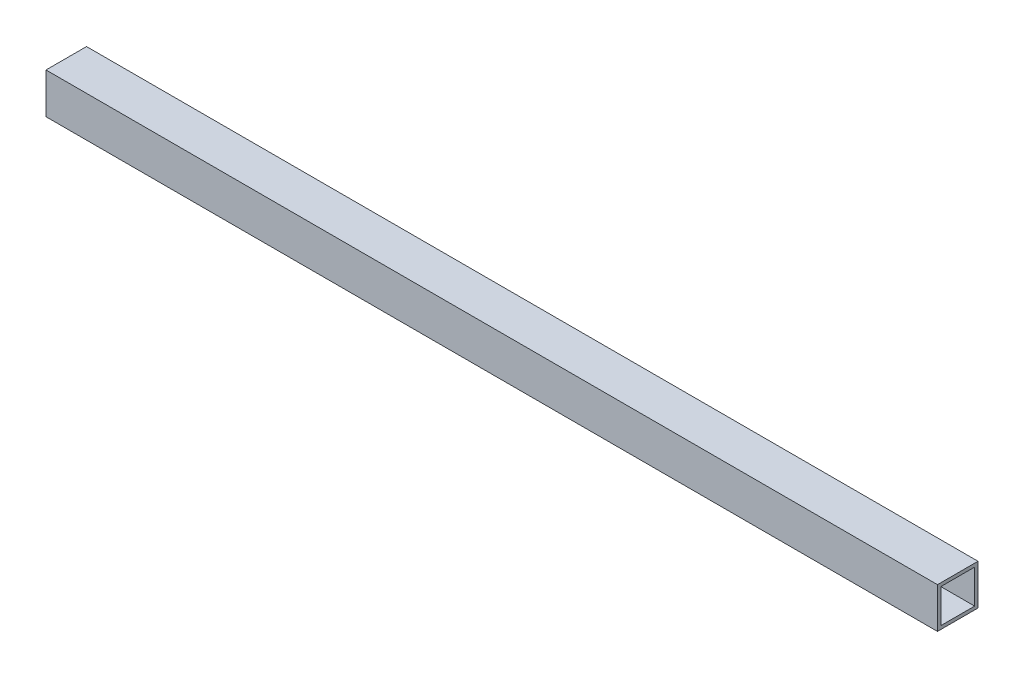
from build123d import *

# Parameters (mm, degrees)
SKETCH1_W               = 838.1
SKETCH1_H               = 38.1
BOSS_EXTRUDE1_DEPTH     = 38.1
SKETCH2_W               = 31.75
SKETCH2_H               = 31.75
CUT_EXTRUDE1_DEPTH      = 1
CUT_EXTRUDE1_DEPTH_BACK = 839.1


with BuildPart() as part:
    # Sketch1 → Boss-Extrude1 (new body)
    with BuildSketch(Plane.XY):
        with Locations((419.05, 19.05)):
            Rectangle(SKETCH1_W, SKETCH1_H)
    extrude(amount=-BOSS_EXTRUDE1_DEPTH)

    # Sketch2 → Cut-Extrude1 (cut, two sides)
    with BuildSketch(Plane(origin=(838.1, 0, 0), x_dir=(0, 0, -1), z_dir=(1, 0, 0))) as cut_extrude1_sk:
        with Locations((19.05, 19.05)):
            Rectangle(SKETCH2_W, SKETCH2_H)
    extrude(amount=CUT_EXTRUDE1_DEPTH, mode=Mode.SUBTRACT)
    extrude(cut_extrude1_sk.sketch, amount=-CUT_EXTRUDE1_DEPTH_BACK, mode=Mode.SUBTRACT)


solid = part.part
